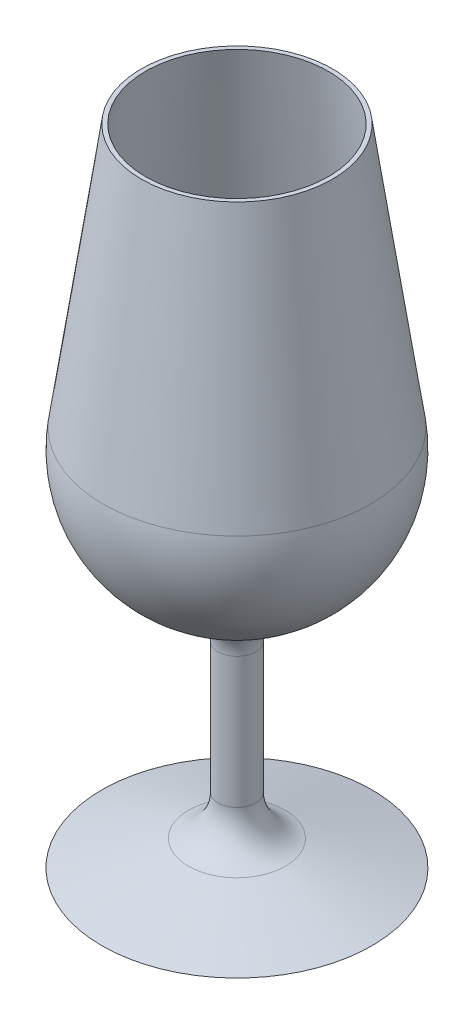
from build123d import *


with BuildPart() as part:
    # Sketch2 → Revolve1 (revolve)
    with BuildSketch(Plane.XY):
        with BuildLine():
            Line((0, -37.091298276), (32.5, -37.091298276))
            Line((32.5, -37.091298276), (11.66645179, -30.935726736))
            ThreePointArc((11.66645179, -30.935726736), (6.489523045, -27.331580559), (4.5, -21.345575301))
            Line((4.5, -21.345575301), (4.5, 10.145686892))
            ThreePointArc((4.5, 10.145686892), (6.311054798, 15.885127323), (11.088235294, 19.545679529))
            ThreePointArc((11.088235294, 19.545679529), (27.887861488, 33.406821561), (32.163132951, 54.762868775))
            Line((32.163132951, 54.762868775), (23, 117.908701724))
            Line((23, 117.908701724), (21.989526299, 117.908701724))
            Line((21.989526299, 117.908701724), (31.173498091, 54.619262216))
            ThreePointArc((31.173498091, 54.619262216), (23.819567674, 29.483081871), (0, 18.595655602))
            Line((0, 18.595655602), (0, -37.091298276))
        make_face()
    revolve(axis=Axis((0, 117.908701724, 0), (0, -1, 0)))


solid = part.part
